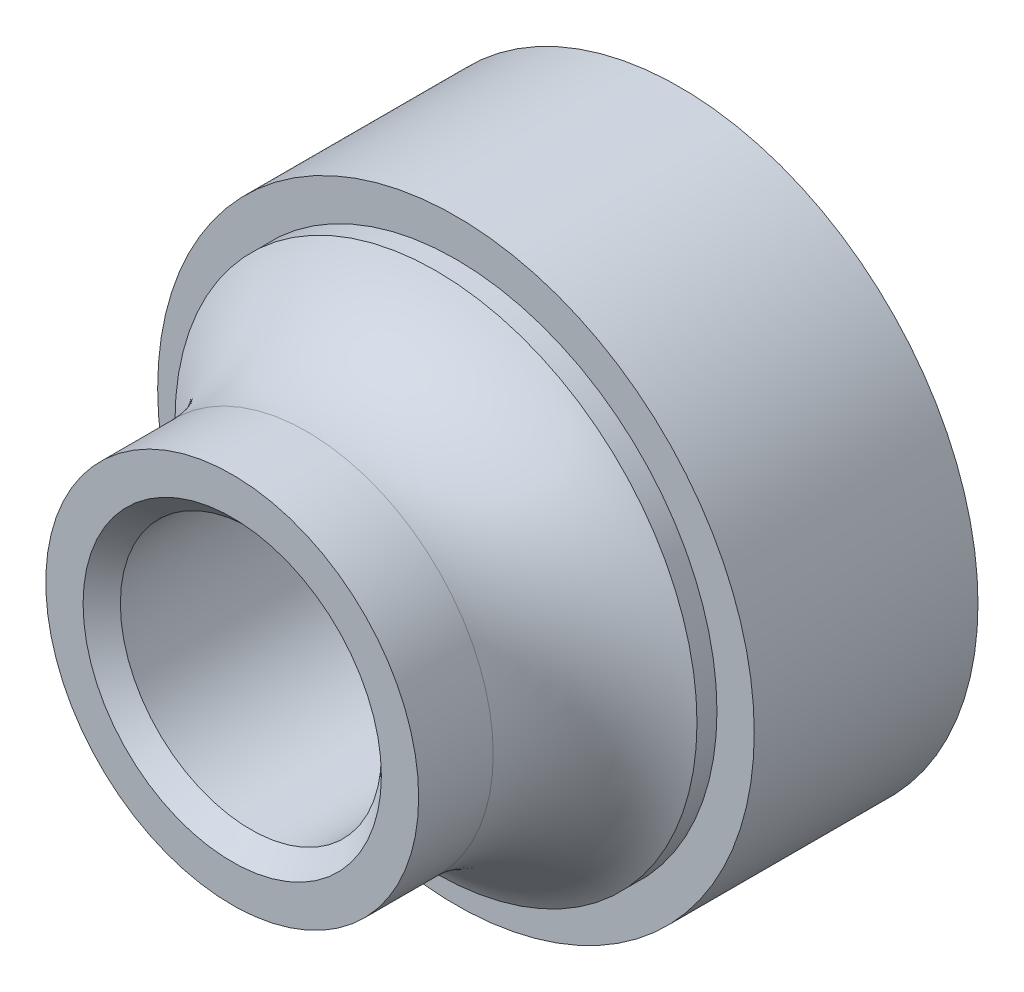
from build123d import *

# Parameters (mm, degrees)
SKETCH_1_R          = 8
EXTRUDE_1_DEPTH     = 6
SKETCH_2_R          = 7
EXTRUDE_2_DEPTH     = 6
SKETCH_4_R          = 3.5
CUT_EXTRUDE_1_DEPTH = 96
CHAMFER_1_SIZE      = 0.5


with BuildPart() as part:
    # Эскиз1 → Вытянуть1 (new body)
    with BuildSketch(Plane.XY):
        Circle(SKETCH_1_R)
    extrude(amount=EXTRUDE_1_DEPTH)

    # Эскиз2 → Вытянуть2 (add)
    with BuildSketch(Plane.XY.offset(6)):
        Circle(SKETCH_2_R)
    extrude(amount=EXTRUDE_2_DEPTH)

    # Эскиз3 → Вырез-Повернуть1 (revolve, cut)
    with BuildSketch(Plane(origin=(0, 0, 0), x_dir=(0, 0, -1), z_dir=(1, 0, 0)), mode=Mode.PRIVATE) as cut_revolve_1_sk:
        with BuildLine():
            Line((-10, 5), (-12, 5))
            Line((-12, 5), (-12, 7))
            Line((-12, 7), (-6.535898385, 7))
            ThreePointArc((-6.535898385, 7), (-8, 5.535898385), (-10, 5))
        make_face()
    revolve(cut_revolve_1_sk.sketch.rotate(Axis((0, 0, 12), (0, 0, -1)), 90), axis=Axis((0, 0, 12), (0, 0, -1)), mode=Mode.SUBTRACT)  # turned: the seam where the file's is

    # Эскиз4 → Вырез-Вытянуть1 (cut)
    with BuildSketch(Plane(origin=(0, 0, 0), x_dir=(-1, 0, 0), z_dir=(0, 0, -1))):
        Circle(SKETCH_4_R)
    extrude(amount=-CUT_EXTRUDE_1_DEPTH, mode=Mode.SUBTRACT)

    # Фаска1
    chamfer_1_edges = [part.edges().sort_by_distance(p)[0] for p in [
        (3.5, 0, 12),
        (3.5, 0, 0),
    ]]
    chamfer(chamfer_1_edges, length=CHAMFER_1_SIZE)


solid = part.part
